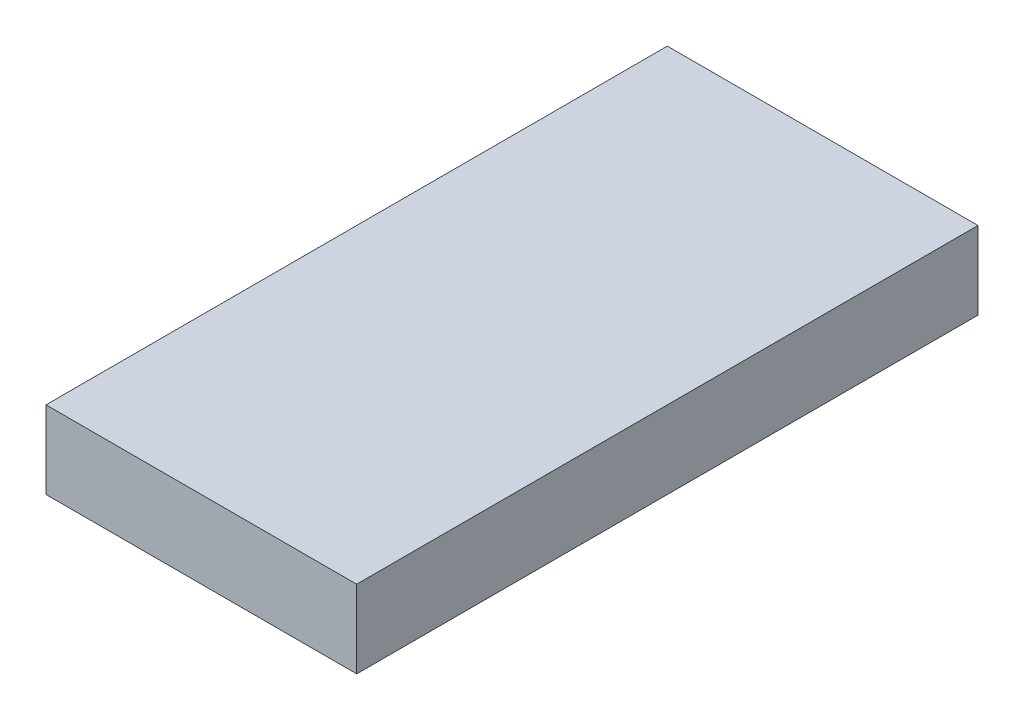
from build123d import *

# Parameters (mm, degrees)
SKETCH1_W           = 3.175
SKETCH1_H           = 6.35
BOSS_EXTRUDE1_DEPTH = 0.79375


with BuildPart() as part:
    # Sketch1 → Boss-Extrude1 (new body)
    with BuildSketch(Plane(origin=(0, 0, 0), x_dir=(1, 0, 0), z_dir=(0, 1, 0))):
        Rectangle(SKETCH1_W, SKETCH1_H)
    extrude(amount=BOSS_EXTRUDE1_DEPTH)


solid = part.part
